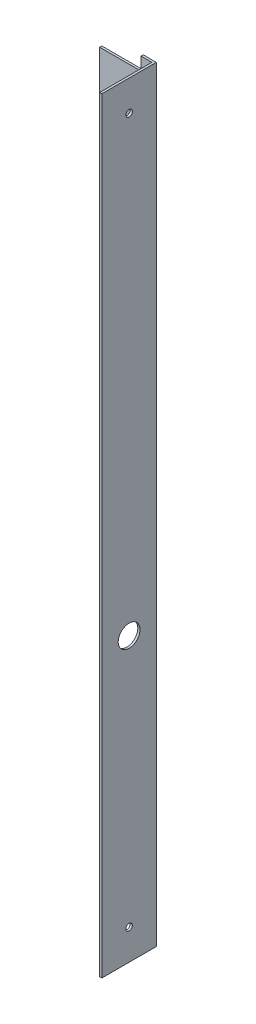
from build123d import *

# Parameters (mm, degrees)
CROQUIS2_W              = 1
CROQUIS2_H              = 352
SALIENTE_EXTRUIR2_DEPTH = 25
CROQUIS5_R              = 1.5
CROQUIS5_R_2            = 5
CORTAR_EXTRUIR2_DEPTH   = 1
SALIENTE_EXTRUIR3_DEPTH = 1


with BuildPart() as part:
    # Croquis2 → Saliente-Extruir2 (new body)
    with BuildSketch(Plane.XY):
        with Locations((-55.840004841, -113.819624774)):
            Rectangle(CROQUIS2_W, CROQUIS2_H)
    extrude(amount=SALIENTE_EXTRUIR2_DEPTH)

    # Croquis5 → Cortar-Extruir2 (cut)
    with BuildSketch(Plane(origin=(-55.340004841, 0, 0), x_dir=(0, 0, -1), z_dir=(1, 0, 0))):
        with Locations((-12.5, 48.180375226)):
            Circle(CROQUIS5_R)
        with Locations((-12.5, -275.819624774)):
            Circle(CROQUIS5_R)
        with Locations((-12.5, -159.819624774)):
            Circle(CROQUIS5_R_2)
    extrude(amount=-CORTAR_EXTRUIR2_DEPTH, mode=Mode.SUBTRACT)

    # Croquis1 → Saliente-Extruir3 (add)
    with BuildSketch(Plane.XY):
        Polygon((-56.340004841, 62.180375226), (-61.340004841, 62.180375226), (-61.340004841, 56.180375226), (-80.340004841, 56.180375226), (-80.340004841, -13.819624774), (-61.340004841, -13.819624774), (-61.340004841, -213.819624774), (-80.340004841, -213.819624774), (-80.340004841, -283.819624774), (-61.340004841, -283.819624774), (-61.340004841, -289.819624774), (-56.340004841, -289.819624774), align=None)
    extrude(amount=SALIENTE_EXTRUIR3_DEPTH)


solid = part.part
